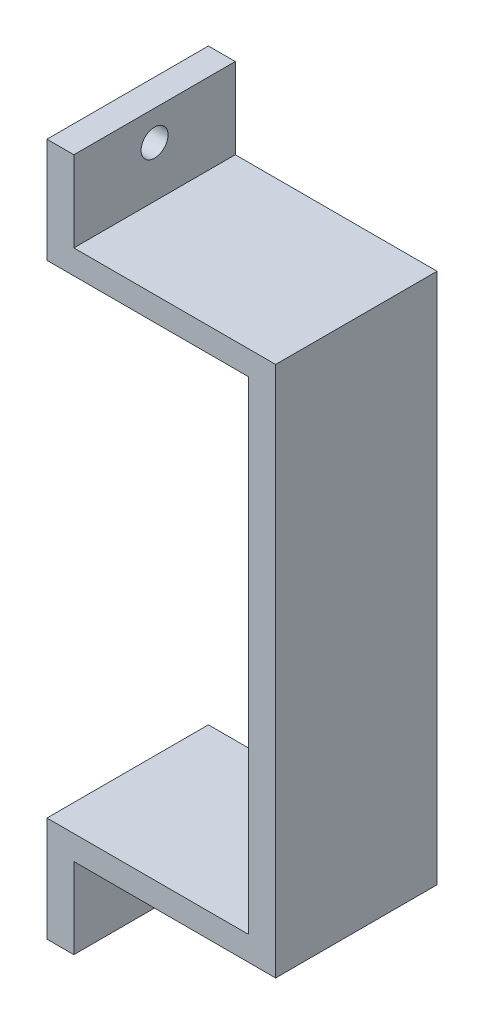
from build123d import *

# Parameters (mm, degrees)
EXTRUDE_1_DEPTH     = 12
SKETCH_2_R          = 1
CUT_EXTRUDE_1_DEPTH = 3


with BuildPart() as part:
    # 草图1 → 凸台-拉伸1 (new body)
    with BuildSketch(Plane.XY):
        Polygon((0, 25.75), (0, 17.95), (15, 17.95), (15, -17.95), (0, -17.95), (0, -25.75), (2, -25.75), (2, -19.75), (17, -19.75), (17, 19.75), (2, 19.75), (2, 25.75), align=None)
    extrude(amount=EXTRUDE_1_DEPTH)

    # 草图2 → 切除-拉伸1 (cut)
    with BuildSketch(Plane.ZY):
        with Locations((6, 23.531116708)):
            Circle(SKETCH_2_R)
        with Locations((6, -22.75)):
            Circle(SKETCH_2_R)
    extrude(amount=-CUT_EXTRUDE_1_DEPTH, mode=Mode.SUBTRACT)


solid = part.part
